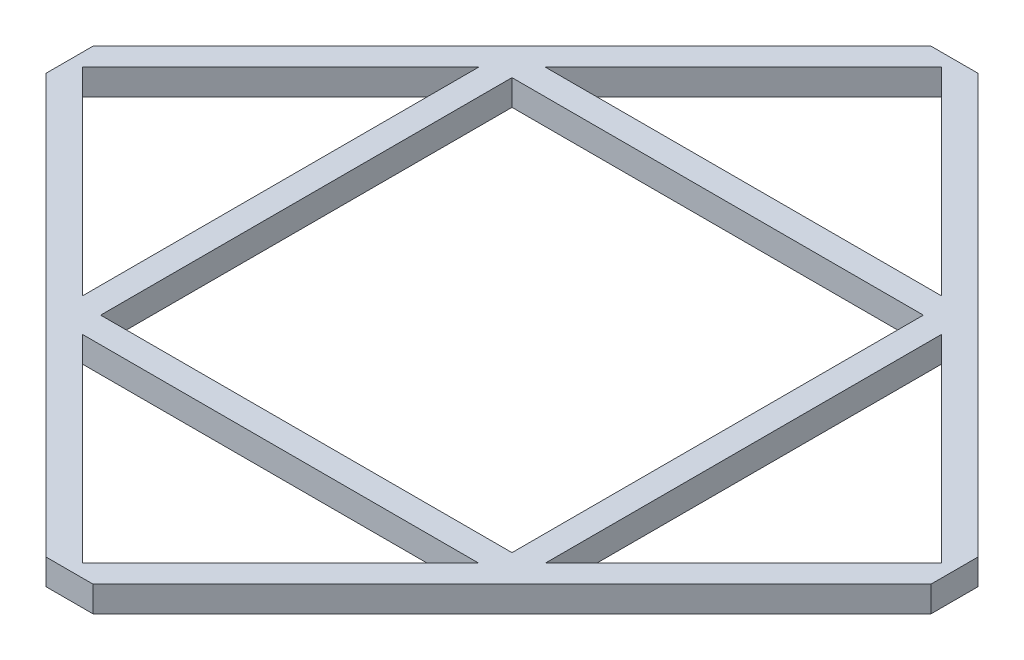
from build123d import *

# Parameters (mm, degrees)
SKETCH2_W           = 6388.157287526
SKETCH2_H           = 6388.157287526
BOSS_EXTRUDE1_DEPTH = 400


with BuildPart() as part:
    # Sketch2 → Boss-Extrude1 (new body)
    with BuildSketch(Plane(origin=(0, 0, 0), x_dir=(1, 0, 0), z_dir=(0, 1, 0))):
        Polygon((-365.685424949, 6871), (-6871, 365.685424949), (-6871, -365.685424949), (-365.685424949, -6871), (365.685424949, -6871), (6871, -365.685424949), (6871, 365.685424949), (365.685424949, 6871), align=None)
        Polygon((3076.921356237, -3594.078643763), (0, -6671), (-3076.921356237, -3594.078643763), align=None, mode=Mode.SUBTRACT)
        Polygon((3594.078643763, 3076.921356237), (6671, 0), (3594.078643763, -3076.921356237), align=None, mode=Mode.SUBTRACT)
        Polygon((-3594.078643763, -3076.921356237), (-6671, 0), (-3594.078643763, 3076.921356237), align=None, mode=Mode.SUBTRACT)
        Rectangle(SKETCH2_W, SKETCH2_H, mode=Mode.SUBTRACT)
        Polygon((3076.921356237, 3594.078643763), (-3076.921356237, 3594.078643763), (0, 6671), align=None, mode=Mode.SUBTRACT)
    extrude(amount=BOSS_EXTRUDE1_DEPTH)


solid = part.part
